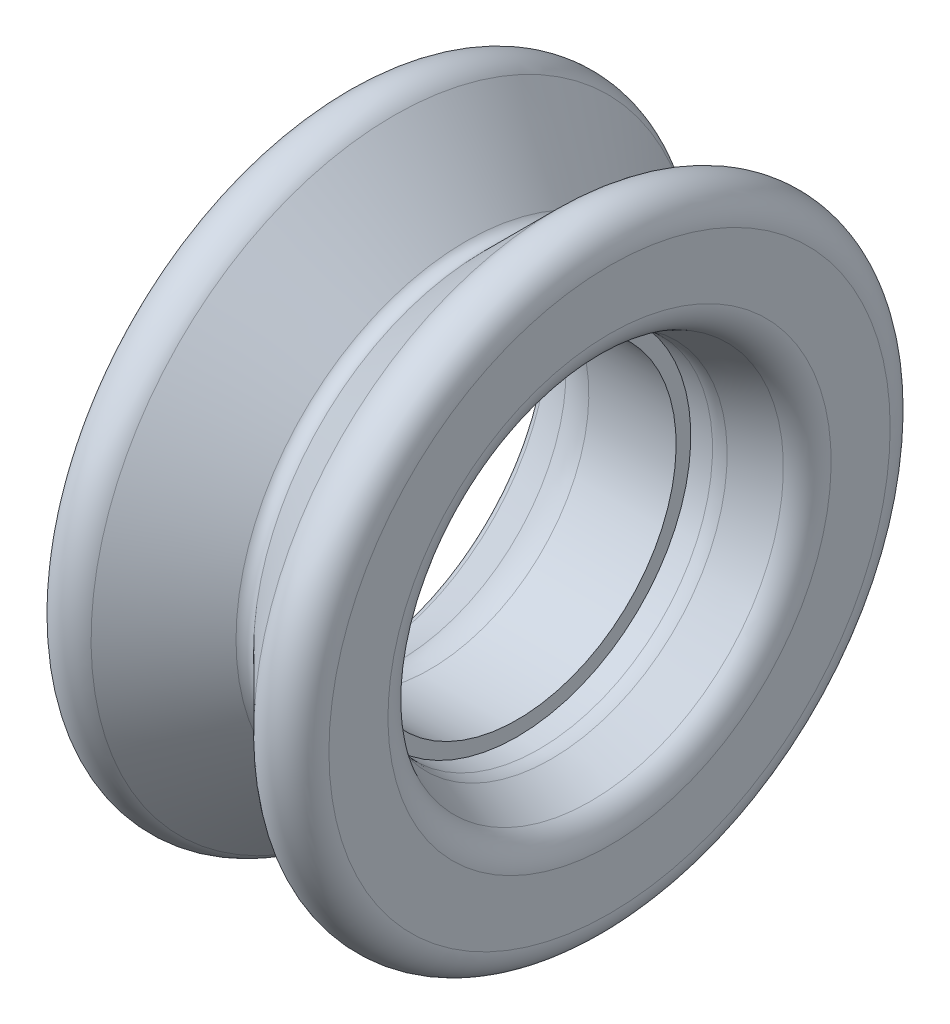
from build123d import *

# Parameters (mm, degrees)
FILLET3_R = 1.27
FILLET4_R = 1.27


with BuildPart() as part:
    # Sketch1 → Revolve1 (revolve)
    with BuildSketch(Plane.XY):
        with BuildLine():
            Line((-4.699, 6.477), (-1.143, 6.477))
            Line((-1.143, 6.477), (-1.143, 7.0739))
            Line((-1.143, 7.0739), (0, 7.0739))
            Line((0, 7.0739), (2.621551224, 8.184201811))
            Line((2.621551224, 8.184201811), (2.621551224, 11.43))
            ThreePointArc((2.621551224, 11.43), (1.837559183, 12.603327006), (0.453525612, 12.328025612))
            Line((0.453525612, 12.328025612), (-2.498289755, 9.376210245))
            ThreePointArc((-2.498289755, 9.376210245), (-2.8575, 9.22742049), (-3.216710245, 9.376210245))
            Line((-3.216710245, 9.376210245), (-6.168525612, 12.328025612))
            ThreePointArc((-6.168525612, 12.328025612), (-7.552559183, 12.603327006), (-8.336551224, 11.43))
            Line((-8.336551224, 11.43), (-8.336551224, 8.184201811))
            Line((-8.336551224, 8.184201811), (-5.969, 6.817295474))
            ThreePointArc((-5.969, 6.817295474), (-5.356400375, 6.563548401), (-4.699, 6.477))
        make_face()
    revolve(axis=Axis((0, 0, 0), (-1, 0, 0)))

    # Fillet3
    fillet3_edges = [part.edges().sort_by_distance(p)[0] for p in [
        (2.621551224, -8.184201811, 0),
        (-8.336551224, -8.184201811, 0),
    ]]
    fillet(fillet3_edges, radius=FILLET3_R)

    # Fillet4
    fillet4_edges = [part.edges().sort_by_distance(p)[0] for p in [
        (0, -7.0739, 0),
    ]]
    fillet(fillet4_edges, radius=FILLET4_R)


solid = part.part
